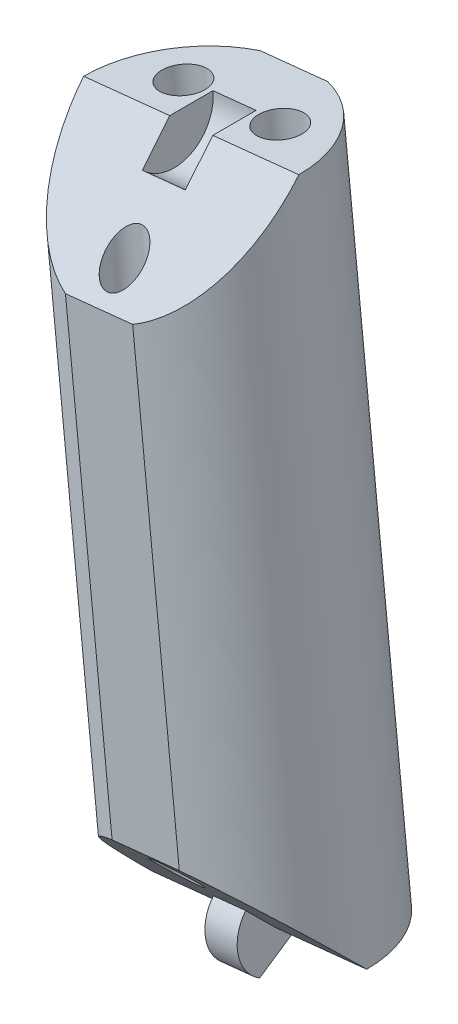
from build123d import *

# Parameters (mm, degrees)
SKETCH3_R               = 8
BOSS_EXTRUDE1_DEPTH     = 48.633157895
CUT_EXTRUDE1_DEPTH      = 13.989776257
CUT_EXTRUDE1_DEPTH_BACK = 13.989776257
BOSS_EXTRUDE2_DEPTH     = 1.2
CUT_EXTRUDE2_DEPTH      = 1.6
SKETCH8_R               = 1.4
SKETCH8_R_2             = 1.6
CUT_EXTRUDE3_DEPTH      = 2.64160469
CUT_EXTRUDE3_DEPTH_BACK = 52.97615102
CUT_EXTRUDE4_DEPTH      = 52.97615102


with BuildPart() as part:
    # Sketch3 → Boss-Extrude1 (new body)
    with BuildSketch(Plane(origin=(-20.344467381, 196.178792599, 0), x_dir=(-0.994665758, -0.103150523, 0), z_dir=(0.103150523, -0.994665758, 0))):
        with Locations((-10.431405186, 0)):
            Circle(SKETCH3_R)
    extrude(amount=BOSS_EXTRUDE1_DEPTH)

    # Sketch4 → Cut-Extrude1 (cut, two sides)
    with BuildSketch(Plane(origin=(10.375761543, 1.076004901, 0), x_dir=(0.103150523, -0.994665758, 0), z_dir=(-0.994665758, -0.103150523, 0))) as cut_extrude1_sk:
        Polygon((-197.230869842, 0), (-189.230869842, 8), (-197.230869842, 8), align=None)
        Polygon((-156.597711947, 8), (-148.597711947, 8), (-148.597711947, 0), align=None)
    extrude(amount=CUT_EXTRUDE1_DEPTH, mode=Mode.SUBTRACT)
    extrude(cut_extrude1_sk.sketch, amount=-CUT_EXTRUDE1_DEPTH_BACK, mode=Mode.SUBTRACT)

    # Sketch5 → Boss-Extrude2 (add, symmetric)
    with BuildSketch(Plane(origin=(10.375761543, 1.076004901, 0), x_dir=(0.103150523, -0.994665758, 0), z_dir=(-0.994665758, -0.103150523, 0))):
        with BuildLine():
            Line((-148.597711947, -2.8), (-146.172840817, 1.4))
            ThreePointArc((-146.172840817, 1.4), (-148.232238609, 2.776045612), (-150.577610935, 1.979898987))
            Line((-150.577610935, 1.979898987), (-148.597711947, 0))
            Line((-148.597711947, 0), (-148.597711947, -2.8))
        make_face()
    extrude(amount=BOSS_EXTRUDE2_DEPTH, both=True)

    # Sketch7 → Cut-Extrude2 (cut, symmetric)
    with BuildSketch(Plane(origin=(10.375761543, 1.076004901, 0), x_dir=(0.103150523, -0.994665758, 0), z_dir=(-0.994665758, -0.103150523, 0))):
        with BuildLine():
            Line((-194.968128142, 2.2627417), (-197.230869842, 0))
            Line((-197.230869842, 0), (-197.230869842, -3.2))
            ThreePointArc((-197.230869842, -3.2), (-194.274455338, -1.224586984), (-194.968128142, 2.2627417))
        make_face()
    extrude(amount=CUT_EXTRUDE2_DEPTH, both=True, mode=Mode.SUBTRACT)

    # Sketch8 → Cut-Extrude3 (cut, two sides)
    with BuildSketch(Plane(origin=(-20.344467381, 196.178792599, 0), x_dir=(0.994665758, 0.103150523, 0), z_dir=(-0.103150523, 0.994665758, 0))) as cut_extrude3_sk:
        with Locations((10.431405186, -5.5)):
            Circle(SKETCH8_R)
        with Locations((6.831405186, 3)):
            Circle(SKETCH8_R_2)
        with Locations((14.031405186, 3)):
            Circle(SKETCH8_R_2)
    extrude(amount=CUT_EXTRUDE3_DEPTH, mode=Mode.SUBTRACT)
    extrude(cut_extrude3_sk.sketch, amount=-CUT_EXTRUDE3_DEPTH_BACK, mode=Mode.SUBTRACT)

    # Sketch9 → Cut-Extrude4 (cut, through all)
    with BuildSketch(Plane(origin=(-20.344467381, 196.178792599, 0), x_dir=(0.994665758, 0.103150523, 0), z_dir=(-0.103150523, 0.994665758, 0))):
        with BuildLine():
            Line((7.933405986, 7.6), (12.929404385, 7.6))
            ThreePointArc((12.929404385, 7.6), (10.431405186, 8), (7.933405986, 7.6))
        make_face()
        with BuildLine():
            Line((7.933405986, -7.6), (12.929404385, -7.6))
            ThreePointArc((12.929404385, -7.6), (10.431405186, -8), (7.933405986, -7.6))
        make_face()
    extrude(amount=-CUT_EXTRUDE4_DEPTH, mode=Mode.SUBTRACT)


solid = part.part
